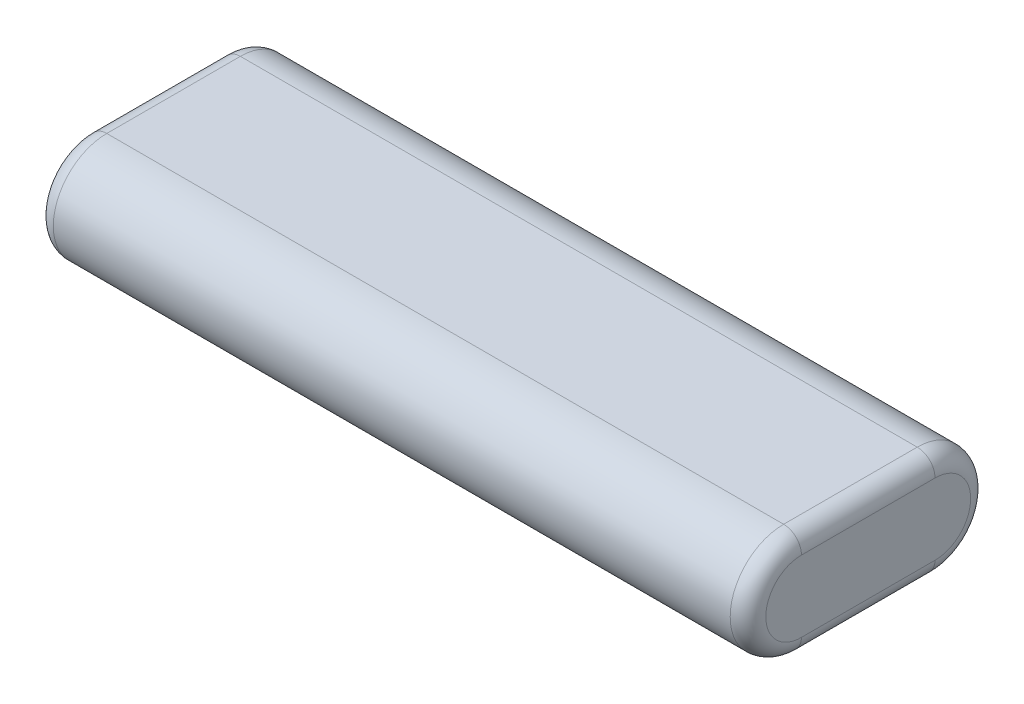
from build123d import *

# Parameters (mm, degrees)
SKETCH1_W           = 23.8125
SKETCH1_H           = 19.05
BOSS_EXTRUDE1_DEPTH = 63.5
FILLET1_R           = 3.175


with BuildPart() as part:
    # Sketch1 → Boss-Extrude1 (new body, symmetric)
    with BuildSketch(Plane(origin=(0, 0, 0), x_dir=(0, 0, -1), z_dir=(1, 0, 0))):
        with BuildLine():
            Line((-11.90625, -9.525), (-11.90625, 9.525))
            ThreePointArc((-11.90625, 9.525), (-21.43125, 0), (-11.90625, -9.525))
        make_face()
        Rectangle(SKETCH1_W, SKETCH1_H)
        with BuildLine():
            ThreePointArc((11.90625, 9.525), (21.43125, 0), (11.90625, -9.525))
            Line((11.90625, -9.525), (11.90625, 9.525))
        make_face()
    extrude(amount=BOSS_EXTRUDE1_DEPTH, both=True)

    # Fillet1
    fillet1_edges = [part.edges().sort_by_distance(p)[0] for p in [
        (63.5, 0, -21.43125),
        (63.5, 9.525, 0),
        (63.5, 0, 21.43125),
        (-63.5, 9.525, 0),
        (-63.5, 0, -21.43125),
        (-63.5, -9.525, 0),
        (-63.5, 0, 21.43125),
        (63.5, -9.525, 0),
    ]]
    fillet(fillet1_edges, radius=FILLET1_R)


solid = part.part
